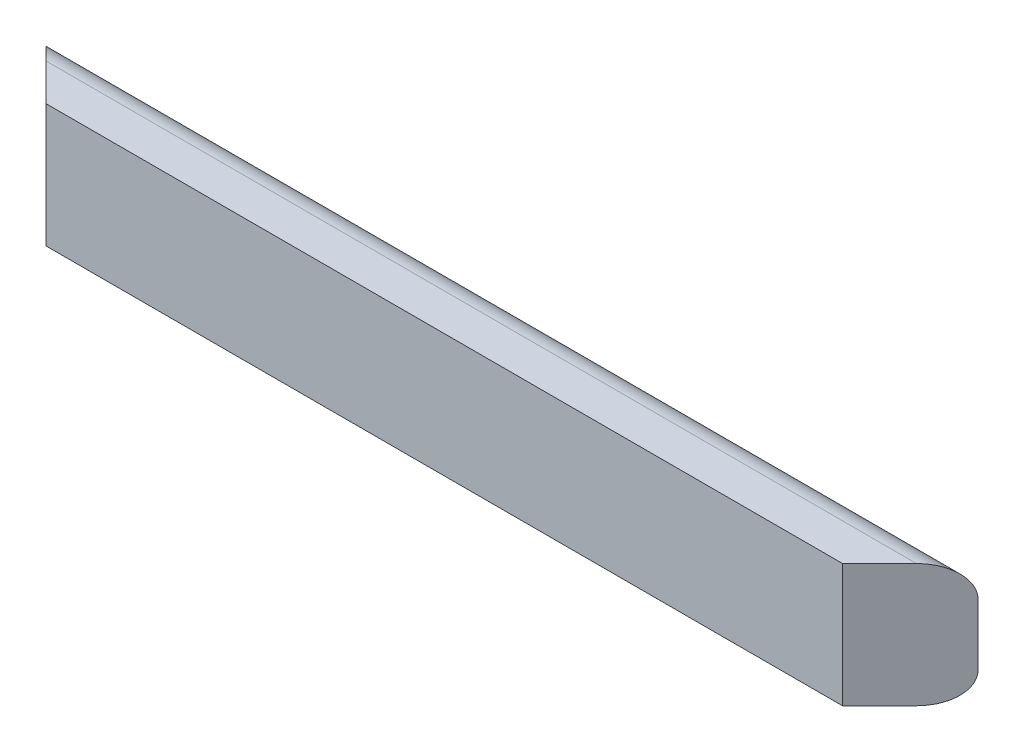
from build123d import *

# Parameters (mm, degrees)
BOSS_EXTRUDE1_DEPTH      = 480.1870635
BOSS_EXTRUDE1_DEPTH_BACK = 480.1870635
CUT_EXTRUDE1_DEPTH       = 128
BOSS_EXTRUDE3_DEPTH      = 0.254


with BuildPart() as part:
    # Sketch1 → Boss-Extrude1 (new body, two sides)
    with BuildSketch(Plane(origin=(0, 0, 0), x_dir=(0, 0, -1), z_dir=(1, 0, 0))) as boss_extrude1_sk:
        with BuildLine():
            Line((6.35, 127), (38.1, 127))
            ThreePointArc((38.1, 127), (60.550640303, 117.700640303), (69.85, 95.25))
            Line((69.85, 95.25), (69.85, 31.75))
            ThreePointArc((69.85, 31.75), (60.550640303, 9.299359697), (38.1, 0))
            Line((38.1, 0), (6.35, 0))
            Line((6.35, 0), (0, 0))
            Line((0, 0), (0, 127))
            Line((0, 127), (6.35, 127))
        make_face()
    extrude(amount=BOSS_EXTRUDE1_DEPTH)
    extrude(boss_extrude1_sk.sketch, amount=-BOSS_EXTRUDE1_DEPTH_BACK)

    # Sketch2 → Cut-Extrude1 (cut, through all)
    with BuildSketch(Plane(origin=(0, 127, 0), x_dir=(1, 0, 0), z_dir=(0, 1, 0))):
        Polygon((480.1870635, 69.85), (410.3370635, 0), (480.1870635, 0), align=None)
        Polygon((-480.1870635, 69.85), (-410.3370635, 0), (-480.1870635, 0), align=None)
    extrude(amount=-CUT_EXTRUDE1_DEPTH, mode=Mode.SUBTRACT)

    # Sketch4 → Boss-Extrude3 (add)
    with BuildSketch(Plane(origin=(0, 0, -69.85), x_dir=(-1, 0, 0), z_dir=(0, 0, -1))):
        with BuildLine():
            Line((-141.487283737, 49.988561174), (-129.139597752, 51.506297576))
            add(Edge.make_bspline(
                [(-129.139597752, 51.506297576), (-129.032962671, 50.747064564), (-128.830554263, 49.305933343), (-128.199436765, 47.311224862), (-127.375544429, 45.575399002), (-126.284752313, 44.15314528), (-125.023613015, 43.021998512), (-123.617151139, 42.214884132), (-122.078088821, 41.705902447), (-121.006107171, 41.654466058), (-120.457631044, 41.628148788)],
                knots=[0, 0, 0, 0, 0.002296393, 0.004358878, 0.006251366, 0.008031558, 0.009698934, 0.011300675, 0.012866747, 0.014507519, 0.014507519, 0.014507519, 0.014507519], degree=3))
            add(Edge.make_bspline(
                [(-120.457631044, 41.628148788), (-120.161330426, 41.634511687), (-119.574405191, 41.647115596), (-118.711610093, 41.779355342), (-117.882599365, 41.996726001), (-117.095552411, 42.309506181), (-116.34671202, 42.698139812), (-115.626217183, 43.160949602), (-114.964334496, 43.738979779), (-114.318123207, 44.37140603), (-113.74466798, 45.091318713), (-113.239522217, 45.872393773), (-112.796104536, 46.706884108), (-112.452410387, 47.616306001), (-112.18337499, 48.58096015), (-111.991040418, 49.605033933), (-111.873985761, 50.684667137), (-111.859983423, 51.424537153), (-111.852837373, 51.802127553)],
                knots=[0, 0, 0, 0, 0.000888328, 0.00175964, 0.002611364, 0.003454499, 0.00429439, 0.005139876, 0.006016016, 0.006925509, 0.007849529, 0.008769961, 0.009713469, 0.010678475, 0.011680239, 0.012714505, 0.013801111, 0.01493364, 0.01493364, 0.01493364, 0.01493364], degree=3))
            add(Edge.make_bspline(
                [(-111.852837373, 51.802127553), (-111.879604371, 52.502912818), (-111.930665339, 53.839737143), (-112.325229706, 55.7363289), (-113.009474812, 57.403510016), (-113.968135732, 58.811372072), (-115.107297702, 59.943891395), (-116.38339385, 60.795183755), (-117.808484904, 61.284244815), (-118.799184723, 61.350799485), (-119.300035483, 61.384446364)],
                knots=[0, 0, 0, 0, 0.002101303, 0.004008464, 0.005778497, 0.007473037, 0.009082865, 0.010570546, 0.01203892, 0.013540272, 0.013540272, 0.013540272, 0.013540272], degree=3))
            add(Edge.make_bspline(
                [(-119.300035483, 61.384446364), (-119.656610092, 61.375322265), (-120.412510639, 61.355980138), (-121.58827301, 61.155013218), (-122.870446973, 60.877669799), (-123.74350999, 60.610883817), (-124.200523358, 60.471232088)],
                knots=[0, 0, 0, 0, 0.001068799, 0.002265742, 0.003570159, 0.005003007, 0.005003007, 0.005003007, 0.005003007], degree=3))
            Line((-124.200523358, 60.471232088), (-123.042927797, 70.439416087))
            add(Edge.make_bspline(
                [(-123.042927797, 70.439416087), (-122.699793823, 70.433529916), (-122.033943987, 70.422107829), (-121.061603486, 70.502723798), (-120.151462794, 70.649910548), (-119.305645566, 70.888720241), (-118.523364253, 71.178445171), (-117.797777169, 71.542462959), (-117.146635388, 71.995464307), (-116.353828061, 72.679267448), (-115.542714487, 73.703905506), (-114.809416499, 75.108914451), (-114.400837558, 76.710921704), (-114.349142899, 77.832955884), (-114.32237457, 78.413963285)],
                knots=[0, 0, 0, 0, 0.001028974, 0.001996719, 0.002922885, 0.00379039, 0.004628901, 0.005422717, 0.006218303, 0.007002368, 0.008557149, 0.01010457, 0.011726837, 0.013468984, 0.013468984, 0.013468984, 0.013468984], degree=3))
            add(Edge.make_bspline(
                [(-114.32237457, 78.413963285), (-114.340421784, 78.908707793), (-114.375026012, 79.857344611), (-114.685449372, 81.207210903), (-115.215277515, 82.398975794), (-115.956386082, 83.411952531), (-116.865477663, 84.234520651), (-117.928062929, 84.842338565), (-119.145149606, 85.196777383), (-120.000810014, 85.236190038), (-120.444768871, 85.256639269)],
                knots=[0, 0, 0, 0, 0.001482725, 0.002843017, 0.004126788, 0.00536937, 0.00658067, 0.007778787, 0.009012014, 0.010341865, 0.010341865, 0.010341865, 0.010341865], degree=3))
            add(Edge.make_bspline(
                [(-120.444768871, 85.256639269), (-120.889846441, 85.23463774), (-121.764714725, 85.191390357), (-123.016587755, 84.763605166), (-124.171507752, 84.101718979), (-125.190641675, 83.153836406), (-126.073947139, 81.974913825), (-126.758445098, 80.537127716), (-127.240501283, 78.863003816), (-127.406174904, 77.658066607), (-127.493239621, 77.024848612)],
                knots=[0, 0, 0, 0, 0.001331033, 0.00261635, 0.003924566, 0.005299375, 0.00676052, 0.008319445, 0.010049157, 0.01196493, 0.01196493, 0.01196493, 0.01196493], degree=3))
            Line((-127.493239621, 77.024848612), (-139.840925606, 78.87700151))
            add(Edge.make_bspline(
                [(-139.840925606, 78.87700151), (-139.637325698, 79.819720317), (-139.247589866, 81.624295295), (-138.451300452, 84.152640803), (-137.51697339, 86.384586473), (-136.425350386, 88.345144228), (-135.132300003, 90.068833733), (-133.597053466, 91.56499453), (-131.842580673, 92.877041648), (-129.872231734, 93.976422082), (-127.72989182, 94.857582736), (-125.449924009, 95.509752612), (-123.038143208, 95.883504452), (-121.389271871, 95.93280399), (-120.547666254, 95.957967122)],
                knots=[0, 0, 0, 0, 0.002892188, 0.005536295, 0.007939595, 0.010139628, 0.012251611, 0.014379902, 0.016548466, 0.018805951, 0.021130057, 0.023483378, 0.025904646, 0.028428911, 0.028428911, 0.028428911, 0.028428911], degree=3))
            add(Edge.make_bspline(
                [(-120.547666254, 95.957967122), (-119.826495707, 95.941556837), (-118.417458275, 95.909494092), (-116.362747759, 95.633600563), (-114.418641852, 95.185408458), (-112.582430461, 94.55140964), (-110.845601518, 93.744182635), (-109.237149801, 92.728555989), (-107.723332756, 91.556250599), (-106.826681472, 90.643909975), (-106.373551717, 90.18285149)],
                knots=[0, 0, 0, 0, 0.00216272, 0.004225566, 0.006206716, 0.008138827, 0.010043341, 0.01193845, 0.013834781, 0.015772193, 0.015772193, 0.015772193, 0.015772193], degree=3))
            add(Edge.make_bspline(
                [(-106.373551717, 90.18285149), (-106.023537684, 89.789960912), (-105.332223658, 89.013961265), (-104.434645502, 87.76983024), (-103.683420883, 86.477065821), (-103.046188148, 85.162642075), (-102.572302428, 83.796078916), (-102.21901684, 82.398827932), (-102.009177681, 80.958508612), (-101.986217703, 79.983817154), (-101.974688585, 79.494385809)],
                knots=[0, 0, 0, 0, 0.001577859, 0.003116435, 0.004592226, 0.006059303, 0.007491227, 0.008923094, 0.010378283, 0.01184598, 0.01184598, 0.01184598, 0.01184598], degree=3))
            add(Edge.make_bspline(
                [(-101.974688585, 79.494385809), (-101.999837567, 78.805967701), (-102.049410836, 77.448969012), (-102.504305984, 75.474938782), (-103.235446067, 73.608860109), (-104.24640348, 71.843604558), (-105.564457117, 70.195553035), (-107.18702939, 68.679534469), (-109.066442264, 67.237696856), (-110.47902046, 66.423262632), (-111.209728728, 66.001966436)],
                knots=[0, 0, 0, 0, 0.002062805, 0.004066169, 0.006041465, 0.008057998, 0.010145081, 0.012346731, 0.014705704, 0.017233636, 0.017233636, 0.017233636, 0.017233636], degree=3))
            add(Edge.make_bspline(
                [(-111.209728728, 66.001966436), (-110.774920169, 65.897167744), (-109.916890308, 65.690363151), (-108.677362831, 65.268754117), (-107.51653992, 64.727943501), (-106.405990923, 64.133720127), (-105.373275352, 63.429091991), (-104.398375528, 62.648317715), (-103.518575507, 61.746303626), (-102.675530041, 60.793323049), (-101.938600577, 59.747465525), (-101.272737218, 58.65913874), (-100.737902273, 57.501788739), (-100.280457077, 56.30517302), (-99.939604466, 55.04995027), (-99.672693466, 53.745511556), (-99.538908832, 52.383737677), (-99.516490646, 51.459364418), (-99.505151388, 50.99181066)],
                knots=[0, 0, 0, 0, 0.001341433, 0.002647118, 0.003919173, 0.005179731, 0.006421181, 0.007664628, 0.008919728, 0.010196262, 0.011477647, 0.012752625, 0.014018423, 0.015296511, 0.016591573, 0.017915877, 0.019286589, 0.020689509, 0.020689509, 0.020689509, 0.020689509], degree=3))
            add(Edge.make_bspline(
                [(-99.505151388, 50.99181066), (-99.51956021, 50.308923997), (-99.547976345, 48.962179679), (-99.860092867, 46.985641935), (-100.33429342, 45.08605931), (-100.987783847, 43.255757597), (-101.861740077, 41.517130623), (-102.906804937, 39.845787022), (-104.151443825, 38.258375189), (-105.570731672, 36.76692481), (-107.12155314, 35.401826739), (-108.787905722, 34.20277421), (-110.545100916, 33.187927397), (-112.403207023, 32.358101162), (-114.346066599, 31.712439867), (-116.390404873, 31.268680945), (-118.519638929, 30.972625251), (-119.976421673, 30.942228997), (-120.714874502, 30.926820934)],
                knots=[0, 0, 0, 0, 0.002047066, 0.00403709, 0.005986802, 0.007915356, 0.009853836, 0.011813028, 0.013819898, 0.01589426, 0.017981462, 0.020008958, 0.022043053, 0.024058149, 0.026104044, 0.028172975, 0.030326765, 0.03254089, 0.03254089, 0.03254089, 0.03254089], degree=3))
            add(Edge.make_bspline(
                [(-120.714874502, 30.926820934), (-121.414664815, 30.938552975), (-122.789217771, 30.961597466), (-124.80144877, 31.234596831), (-126.728716817, 31.636211012), (-128.559772747, 32.223729356), (-130.310566514, 32.947387314), (-131.948052536, 33.880254279), (-133.514382161, 34.940534945), (-134.958381911, 36.182569084), (-136.300989349, 37.536259204), (-137.480309186, 39.024940262), (-138.531240362, 40.601098684), (-139.435141753, 42.278708256), (-140.184438628, 44.062128348), (-140.767869909, 45.946755571), (-141.23316759, 47.926818682), (-141.401411105, 49.29184333), (-141.487283737, 49.988561174)],
                knots=[0, 0, 0, 0, 0.002097954, 0.004120876, 0.006081039, 0.007996985, 0.009881809, 0.011753244, 0.013640524, 0.015547642, 0.017457664, 0.0193519, 0.021235451, 0.023134528, 0.025059905, 0.027028784, 0.029047531, 0.031152098, 0.031152098, 0.031152098, 0.031152098], degree=3))
        make_face()
        with BuildLine():
            Line((-62.462093433, 50.117182903), (-51.760765579, 51.506297576))
            add(Edge.make_bspline(
                [(-51.760765579, 51.506297576), (-51.642380093, 50.780568), (-51.41440933, 49.383056103), (-50.706719158, 47.432022129), (-49.721163459, 45.713239113), (-48.454544685, 44.265955932), (-47.012973527, 43.088892136), (-45.420400197, 42.249747655), (-43.725063478, 41.721422366), (-42.550922605, 41.659383078), (-41.959789828, 41.628148788)],
                knots=[0, 0, 0, 0, 0.002202138, 0.004240579, 0.006188551, 0.008112424, 0.009978548, 0.011739163, 0.013484868, 0.015254901, 0.015254901, 0.015254901, 0.015254901], degree=3))
            add(Edge.make_bspline(
                [(-41.959789828, 41.628148788), (-41.616370664, 41.634182289), (-40.944122367, 41.645992961), (-39.953467627, 41.780059227), (-39.007120064, 41.997870012), (-38.096125975, 42.293479709), (-37.229973938, 42.682269208), (-36.407893848, 43.158045805), (-35.626813523, 43.721477925), (-34.8827795, 44.358572654), (-34.195286077, 45.085965129), (-33.620713178, 45.923247733), (-33.111714207, 46.827631979), (-32.697063985, 47.823687055), (-32.398158929, 48.914903645), (-32.160358427, 50.082600806), (-32.039139227, 51.340876348), (-32.016273212, 52.204936271), (-32.004468003, 52.651030964)],
                knots=[0, 0, 0, 0, 0.001029697, 0.002015648, 0.002992242, 0.003939949, 0.004884159, 0.005835003, 0.006784455, 0.007769398, 0.008770502, 0.009776797, 0.010807458, 0.011879965, 0.013003622, 0.014196757, 0.015451001, 0.016789656, 0.016789656, 0.016789656, 0.016789656], degree=3))
            add(Edge.make_bspline(
                [(-32.004468003, 52.651030964), (-32.011143045, 53.071527767), (-32.024043665, 53.884207159), (-32.14373122, 55.061642393), (-32.327450959, 56.161966499), (-32.619720064, 57.177134497), (-32.953514389, 58.126018474), (-33.403553287, 58.974986748), (-33.897360682, 59.760920289), (-34.499236907, 60.441413996), (-35.155036013, 61.04267379), (-35.85345981, 61.578386386), (-36.602348538, 62.02538699), (-37.394245331, 62.409044411), (-38.242877677, 62.688498613), (-39.141362088, 62.874418229), (-40.077617441, 63.013987895), (-40.72018881, 63.025139942), (-41.046575552, 63.030804496)],
                knots=[0, 0, 0, 0, 0.001261083, 0.002437252, 0.003547429, 0.004602206, 0.005603309, 0.006558234, 0.007478666, 0.008381312, 0.009273357, 0.010145427, 0.011016739, 0.011885483, 0.012780306, 0.013688525, 0.014636232, 0.015614518, 0.015614518, 0.015614518, 0.015614518], degree=3))
            add(Edge.make_bspline(
                [(-41.046575552, 63.030804496), (-41.45922931, 63.016010253), (-42.282480026, 62.986495507), (-43.497746027, 62.746569399), (-44.680614197, 62.355968027), (-45.829855089, 61.812223729), (-46.94242819, 61.110991483), (-48.013516609, 60.24994579), (-49.061506146, 59.243900895), (-49.705242128, 58.483757088), (-50.03723441, 58.091730101)],
                knots=[0, 0, 0, 0, 0.001237178, 0.002468189, 0.003700611, 0.004966408, 0.006272536, 0.007636473, 0.009082824, 0.010623119, 0.010623119, 0.010623119, 0.010623119], degree=3))
            Line((-50.03723441, 58.091730101), (-60.815735301, 59.609466504))
            Line((-60.815735301, 59.609466504), (-53.40712371, 95.134788057))
            Line((-53.40712371, 95.134788057), (-22.126319215, 95.134788057))
            Line((-22.126319215, 95.134788057), (-22.126319215, 82.787102072))
            Line((-22.126319215, 82.787102072), (-43.503250577, 82.787102072))
            Line((-43.503250577, 82.787102072), (-46.024236465, 71.326906017))
            add(Edge.make_bspline(
                [(-46.024236465, 71.326906017), (-45.381816964, 71.697561885), (-44.130764923, 72.419379607), (-42.133452016, 73.162424748), (-40.125878911, 73.639323084), (-38.77255902, 73.701356019), (-38.101137958, 73.732132349)],
                knots=[0, 0, 0, 0, 0.002221398, 0.004325966, 0.006369797, 0.008382224, 0.008382224, 0.008382224, 0.008382224], degree=3))
            add(Edge.make_bspline(
                [(-38.101137958, 73.732132349), (-37.469945095, 73.715146712), (-36.223094674, 73.681593499), (-34.394484466, 73.406300074), (-32.640499622, 72.952588242), (-30.955217357, 72.321200736), (-29.350691977, 71.493616454), (-27.813091414, 70.49335495), (-26.36461393, 69.303058942), (-24.989696213, 67.957093414), (-23.73586773, 66.467944448), (-22.653087096, 64.844102956), (-21.717878139, 63.126012929), (-20.956507189, 61.294691655), (-20.383173048, 59.347591366), (-19.953801197, 57.301478184), (-19.713270125, 55.1434317), (-19.675867936, 53.671994501), (-19.656782018, 52.921136595)],
                knots=[0, 0, 0, 0, 0.001892882, 0.003739175, 0.005532976, 0.007319892, 0.009126146, 0.010938435, 0.012812652, 0.014740863, 0.016703894, 0.018640964, 0.020586217, 0.022564024, 0.024578299, 0.026666967, 0.028828808, 0.031081488, 0.031081488, 0.031081488, 0.031081488], degree=3))
            add(Edge.make_bspline(
                [(-19.656782018, 52.921136595), (-19.674008435, 52.290478014), (-19.70819943, 51.038746756), (-19.908190569, 49.186441287), (-20.281535625, 47.38868729), (-20.757123097, 45.635357275), (-21.414391177, 43.941141258), (-22.194366108, 42.294994206), (-23.126749606, 40.699872055), (-23.846097598, 39.693450362), (-24.209991225, 39.184335937)],
                knots=[0, 0, 0, 0, 0.001892314, 0.003755865, 0.005579619, 0.007395875, 0.009199379, 0.011023133, 0.012856297, 0.014732985, 0.014732985, 0.014732985, 0.014732985], degree=3))
            add(Edge.make_bspline(
                [(-24.209991225, 39.184335937), (-24.740475206, 38.528772068), (-25.784529389, 37.238546115), (-27.571811387, 35.542219666), (-29.515699496, 34.11760187), (-31.610928766, 32.947630365), (-33.855267088, 32.029523153), (-36.258840659, 31.391212776), (-38.804026141, 30.996298985), (-40.552052993, 30.950317625), (-41.445302912, 30.926820934)],
                knots=[0, 0, 0, 0, 0.002527965, 0.004975329, 0.007367832, 0.009740232, 0.012157396, 0.014622273, 0.017185334, 0.019863756, 0.019863756, 0.019863756, 0.019863756], degree=3))
            add(Edge.make_bspline(
                [(-41.445302912, 30.926820934), (-42.166315783, 30.939844326), (-43.574132764, 30.965273209), (-45.635849187, 31.216745865), (-47.589676133, 31.625295782), (-49.447940052, 32.192240734), (-51.199607305, 32.928566139), (-52.858287962, 33.817543442), (-54.410162381, 34.878876743), (-55.848084307, 36.104548031), (-57.16849389, 37.459270233), (-58.346241116, 38.941581824), (-59.394127645, 40.526691501), (-60.292161634, 42.230616097), (-61.057498838, 44.041405853), (-61.66689253, 45.968341085), (-62.168636561, 47.998571276), (-62.363191729, 49.403162141), (-62.462093433, 50.117182903)],
                knots=[0, 0, 0, 0, 0.002162223, 0.004221858, 0.006219764, 0.008144153, 0.010040833, 0.011911162, 0.013780563, 0.015669552, 0.017570588, 0.019446747, 0.021341026, 0.023262792, 0.025216869, 0.027230322, 0.029320495, 0.031481646, 0.031481646, 0.031481646, 0.031481646], degree=3))
        make_face()
        with BuildLine():
            Line((18.209455003, 47.673370052), (30.557140988, 49.036760379))
            add(Edge.make_bspline(
                [(30.557140988, 49.036760379), (30.637994326, 48.445590088), (30.790823737, 47.328156849), (31.279511065, 45.794795533), (31.892008924, 44.478581747), (32.724355074, 43.419388765), (33.717669119, 42.610927467), (34.855326057, 42.027551658), (36.141865973, 41.691510589), (37.046257906, 41.649795905), (37.515576528, 41.628148788)],
                knots=[0, 0, 0, 0, 0.001786778, 0.003377377, 0.004809705, 0.006119438, 0.007380981, 0.008623496, 0.009927596, 0.011334344, 0.011334344, 0.011334344, 0.011334344], degree=3))
            add(Edge.make_bspline(
                [(37.515576528, 41.628148788), (37.82108926, 41.635229881), (38.424869783, 41.649224147), (39.308127474, 41.846519093), (40.162847532, 42.123113217), (40.980220047, 42.527938781), (41.752430951, 43.048944096), (42.49862858, 43.674368665), (43.195924432, 44.424262543), (43.888543524, 45.285004598), (44.515475303, 46.342388481), (45.068777974, 47.624884025), (45.585382265, 49.132135662), (46.00974389, 50.882888201), (46.391709615, 52.862052998), (46.723999497, 55.075963918), (46.993591195, 57.525973704), (47.112747025, 59.240222456), (47.175068376, 60.136815593)],
                knots=[0, 0, 0, 0, 0.000914662, 0.001807634, 0.002702457, 0.003605561, 0.004533066, 0.005491535, 0.006519624, 0.007600353, 0.008800332, 0.010193787, 0.011784178, 0.013574794, 0.015592803, 0.017830229, 0.020288924, 0.022984984, 0.022984984, 0.022984984, 0.022984984], degree=3))
            add(Edge.make_bspline(
                [(47.175068376, 60.136815593), (46.780053355, 59.712840793), (46.001223909, 58.87691294), (44.71130418, 57.780208753), (43.337872185, 56.858167302), (41.887954292, 56.114969452), (40.376676573, 55.507774121), (38.779192363, 55.108371957), (37.117744626, 54.834342387), (35.981841775, 54.810896119), (35.406180172, 54.799013839)],
                knots=[0, 0, 0, 0, 0.001737346, 0.003425429, 0.005066403, 0.006688669, 0.008305675, 0.009940386, 0.011619429, 0.013344687, 0.013344687, 0.013344687, 0.013344687], degree=3))
            add(Edge.make_bspline(
                [(35.406180172, 54.799013839), (34.775120953, 54.817112148), (33.529147227, 54.852845749), (31.696139942, 55.112365051), (29.930031823, 55.554910939), (28.228003244, 56.168602168), (26.598658471, 56.982018065), (25.021221497, 57.94101676), (23.529542388, 59.101824931), (22.101856176, 60.398882812), (20.817953708, 61.859092441), (19.671322158, 63.424836719), (18.701040457, 65.104727317), (17.91842378, 66.896978746), (17.313156595, 68.790183052), (16.873104289, 70.782750287), (16.615986189, 72.885063224), (16.580967533, 74.323086545), (16.563096872, 75.056936158)],
                knots=[0, 0, 0, 0, 0.001892882, 0.003737337, 0.005540429, 0.007347003, 0.009153211, 0.010995198, 0.012875761, 0.014814709, 0.01677369, 0.018698079, 0.020628477, 0.022580902, 0.024553684, 0.02658216, 0.028694417, 0.03089569, 0.03089569, 0.03089569, 0.03089569], degree=3))
            add(Edge.make_bspline(
                [(16.563096872, 75.056936158), (16.579358734, 75.820994235), (16.611257549, 77.319749302), (16.891105872, 79.504796869), (17.318494615, 81.584769941), (17.956662218, 83.541236382), (18.750769394, 85.39520876), (19.737778026, 87.123436928), (20.884990955, 88.74995874), (22.225559796, 90.226408206), (23.682781679, 91.577954163), (25.254774523, 92.754100647), (26.932418562, 93.73702521), (28.700850793, 94.55387073), (30.573337417, 95.182961466), (32.537911021, 95.631263772), (34.596481997, 95.909234714), (36.001235713, 95.941500809), (36.718121808, 95.957967122)],
                knots=[0, 0, 0, 0, 0.002291236, 0.004494426, 0.006598325, 0.008652451, 0.010657176, 0.012638619, 0.014612281, 0.01661614, 0.018609611, 0.020567241, 0.022493005, 0.024432508, 0.026401135, 0.028407345, 0.030470191, 0.03262006, 0.03262006, 0.03262006, 0.03262006], degree=3))
            add(Edge.make_bspline(
                [(36.718121808, 95.957967122), (37.499663885, 95.936372471), (39.032175865, 95.894027903), (41.278242682, 95.541418364), (43.409401552, 94.941490996), (45.446828539, 94.136998461), (47.361156623, 93.065217924), (49.177290656, 91.771676373), (50.87096538, 90.229965387), (52.471833872, 88.470616193), (53.928355727, 86.437701122), (55.168440749, 84.088178395), (56.223269366, 81.444294852), (57.074690413, 78.500372651), (57.739976139, 75.2571666), (58.199148351, 71.714739072), (58.506399323, 67.872388312), (58.531967639, 65.209451336), (58.545229221, 63.828259215)],
                knots=[0, 0, 0, 0, 0.002343776, 0.004595869, 0.006799058, 0.008974933, 0.011151188, 0.01336408, 0.015649967, 0.01800852, 0.020489052, 0.023130343, 0.025958266, 0.029014839, 0.032311798, 0.035880767, 0.039725094, 0.043867692, 0.043867692, 0.043867692, 0.043867692], degree=3))
            add(Edge.make_bspline(
                [(58.545229221, 63.828259215), (58.52606159, 62.42569891), (58.489028928, 59.715893942), (58.190226205, 55.803928156), (57.717275991, 52.191835176), (57.021911158, 48.886068819), (56.149275747, 45.874742553), (55.051986756, 43.169327234), (53.774007676, 40.755869999), (52.277963864, 38.656593307), (50.633270353, 36.832085623), (48.865538969, 35.251440658), (46.97223569, 33.919424772), (44.969790555, 32.808349363), (42.828262634, 31.976311202), (40.577286451, 31.373516087), (38.210806803, 30.983032523), (36.59105741, 30.945785963), (35.766321013, 30.926820934)],
                knots=[0, 0, 0, 0, 0.004207189, 0.008128465, 0.011762888, 0.015128061, 0.018253595, 0.021155605, 0.023871808, 0.026427111, 0.028867876, 0.03122741, 0.033525567, 0.0357993, 0.038080297, 0.040398523, 0.042781672, 0.045253921, 0.045253921, 0.045253921, 0.045253921], degree=3))
            add(Edge.make_bspline(
                [(35.766321013, 30.926820934), (35.174171393, 30.939007153), (34.012346265, 30.962917083), (32.311353086, 31.155274015), (30.697323837, 31.489528146), (29.175630778, 31.956331344), (27.734397737, 32.530354721), (26.385860646, 33.258599195), (25.129668142, 34.124419027), (23.944430126, 35.101203305), (22.877760377, 36.233459151), (21.896551154, 37.483552941), (21.0163417, 38.863993528), (20.266693516, 40.386646363), (19.574694261, 42.016187918), (19.017259722, 43.788735665), (18.552348211, 45.684288067), (18.325771266, 46.998633491), (18.209455003, 47.673370052)],
                knots=[0, 0, 0, 0, 0.001776145, 0.003484878, 0.005127061, 0.006713859, 0.008254423, 0.009773685, 0.011300604, 0.012825572, 0.014372138, 0.01595711, 0.017587768, 0.019273154, 0.021043188, 0.022893955, 0.024840568, 0.026894089, 0.026894089, 0.026894089, 0.026894089], degree=3))
        make_face()
        with BuildLine():
            add(Edge.make_bspline(
                [(46.197543236, 74.748244008), (46.192995259, 75.156048345), (46.184156267, 75.94861615), (46.033839982, 77.096390923), (45.815742371, 78.171216494), (45.526890624, 79.185016488), (45.123602986, 80.121029748), (44.645261082, 80.993995513), (44.080043896, 81.796913755), (43.209927358, 82.734897139), (42.028819488, 83.744543753), (40.446606524, 84.62152998), (38.74720594, 85.168334822), (37.571066842, 85.226950878), (36.975365266, 85.256639269)],
                knots=[0, 0, 0, 0, 0.001222516, 0.002375959, 0.003465682, 0.004511639, 0.005531731, 0.006516171, 0.007494034, 0.008468254, 0.010348948, 0.012127931, 0.013865086, 0.015647925, 0.015647925, 0.015647925, 0.015647925], degree=3))
            add(Edge.make_bspline(
                [(36.975365266, 85.256639269), (36.419313856, 85.23142671), (35.337020127, 85.1823532), (33.788021298, 84.74130182), (32.38478746, 84.025462088), (31.362675998, 83.19033878), (30.634271685, 82.393802965), (30.177740451, 81.680286507), (29.789011167, 80.884969938), (29.467172874, 80.001072357), (29.213222033, 79.028114768), (29.03316865, 77.960908116), (28.935156065, 76.808046526), (28.919070985, 76.008914616), (28.910782857, 75.59714742)],
                knots=[0, 0, 0, 0, 0.001665242, 0.003241212, 0.004788634, 0.006361504, 0.007172229, 0.008017716, 0.00889206, 0.009823924, 0.01083473, 0.01190469, 0.01306685, 0.014302221, 0.014302221, 0.014302221, 0.014302221], degree=3))
            add(Edge.make_bspline(
                [(28.910782857, 75.59714742), (28.917415948, 75.176645173), (28.93023549, 74.363955259), (29.050489251, 73.186593506), (29.230890108, 72.094168937), (29.523932708, 71.095211047), (29.868235556, 70.175499084), (30.284003604, 69.332237197), (30.811986655, 68.596575836), (31.574683025, 67.724000391), (32.690543429, 66.835776981), (34.203521379, 66.061288394), (35.874923032, 65.582484293), (37.045062605, 65.528157919), (37.644198257, 65.500341693)],
                knots=[0, 0, 0, 0, 0.001261083, 0.002437252, 0.003547429, 0.004577448, 0.005554465, 0.006492081, 0.007387735, 0.008262552, 0.009963961, 0.011626418, 0.013336652, 0.015131144, 0.015131144, 0.015131144, 0.015131144], degree=3))
            add(Edge.make_bspline(
                [(37.644198257, 65.500341693), (38.226442431, 65.523155771), (39.36254862, 65.56767183), (40.978917558, 66.043138479), (42.462749954, 66.772451151), (43.548341231, 67.63319606), (44.3244001, 68.448453183), (44.823887088, 69.148575122), (45.25448236, 69.914845239), (45.59835283, 70.754069815), (45.868798685, 71.658960459), (46.05923458, 72.628038663), (46.177505057, 73.664886876), (46.190717154, 74.379194287), (46.197543236, 74.748244008)],
                knots=[0, 0, 0, 0, 0.001742148, 0.003399373, 0.005009972, 0.006677298, 0.007523567, 0.008380327, 0.009249832, 0.010155132, 0.011095127, 0.012078894, 0.013114359, 0.014221179, 0.014221179, 0.014221179, 0.014221179], degree=3))
        make_face(mode=Mode.SUBTRACT)
        with BuildLine():
            Line((95.588287176, 82.787102072), (95.588287176, 95.134788057))
            Line((95.588287176, 95.134788057), (137.570419525, 95.134788057))
            Line((137.570419525, 95.134788057), (137.570419525, 86.079818334))
            add(Edge.make_bspline(
                [(137.570419525, 86.079818334), (137.132466652, 85.634215576), (136.232161359, 84.718184318), (134.942562083, 83.219008064), (133.633855634, 81.592138761), (132.333408388, 79.815654384), (131.000796599, 77.917617609), (129.694583854, 75.861644239), (128.369791871, 73.674406405), (126.586203006, 70.580554119), (124.501410169, 66.539027103), (122.295809638, 61.515202589), (120.416738972, 56.337091808), (119.130033868, 51.924959688), (118.260657453, 48.388642584), (117.692648976, 45.8028037), (117.214506378, 43.289733693), (116.825537694, 40.845015906), (116.535239413, 38.467535056), (116.30585427, 36.165556823), (116.192685302, 33.933467795), (116.175986043, 32.470381045), (116.167763818, 31.75)],
                knots=[0, 0, 0, 0, 0.001873909, 0.003852218, 0.00592925, 0.008136453, 0.010455678, 0.012885403, 0.015442, 0.018126992, 0.023597712, 0.029074959, 0.034576001, 0.04011137, 0.042853457, 0.045499972, 0.048052846, 0.050526934, 0.052924755, 0.055237444, 0.057465609, 0.059626799, 0.059626799, 0.059626799, 0.059626799], degree=3))
            Line((116.167763818, 31.75), (103.820077833, 31.75))
            add(Edge.make_bspline(
                [(103.820077833, 31.75), (103.861365707, 32.843859978), (103.944400134, 35.043731895), (104.255069304, 38.345667879), (104.743008648, 41.659898836), (105.349062065, 44.994084575), (106.149203658, 48.340108138), (107.062410362, 51.71036421), (108.168622974, 55.086852328), (109.408657623, 58.463116455), (110.777590695, 61.80710167), (112.26953513, 65.077331726), (113.880634103, 68.253404415), (115.589935593, 71.3464789), (117.417324861, 74.34660455), (119.36417774, 77.250523525), (121.402878607, 80.079241784), (122.860574051, 81.884634059), (123.589237582, 82.787102072)],
                knots=[0, 0, 0, 0, 0.003283484, 0.006603445, 0.009943105, 0.013331134, 0.016766105, 0.020260925, 0.023803724, 0.027421289, 0.031049471, 0.034641035, 0.038201651, 0.041730882, 0.045240465, 0.048736445, 0.052217368, 0.055696532, 0.055696532, 0.055696532, 0.055696532], degree=3))
            Line((123.589237582, 82.787102072), (95.588287176, 82.787102072))
        make_face()
    extrude(amount=BOSS_EXTRUDE3_DEPTH)


solid = part.part
